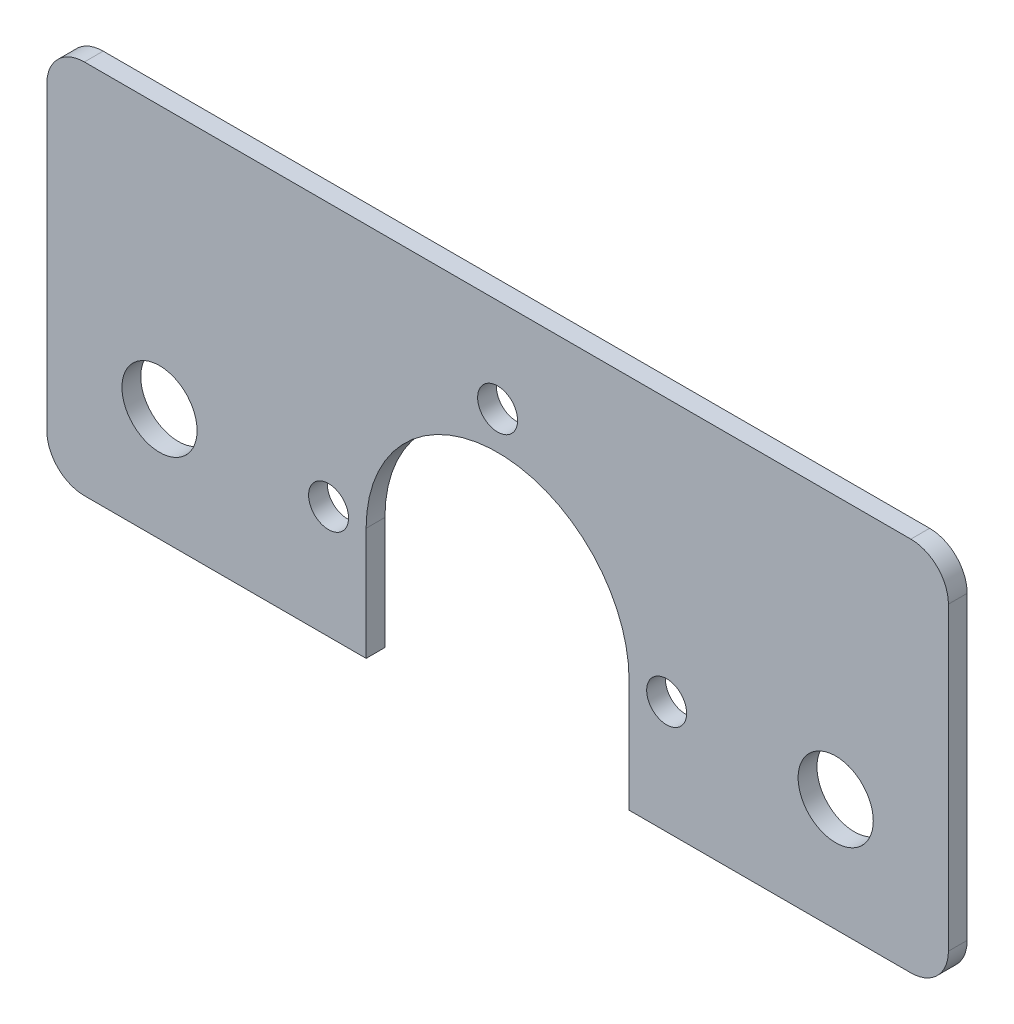
from build123d import *

# Parameters (mm, degrees)
SKETCH1_W           = 152.4
SKETCH1_H           = 88.9
SKETCH1_R           = 3.3782
SKETCH1_R_2         = 6.35
SKETCH1_R_3         = 22.225
BOSS_EXTRUDE1_DEPTH = 3.175
SKETCH2_R           = 3.3782
CUT_EXTRUDE1_DEPTH  = 4.175
SKETCH3_W           = 152.4
SKETCH3_H           = 25.4
CUT_EXTRUDE2_DEPTH  = 4.175
FILLET1_R           = 6.35


with BuildPart() as part:
    # Sketch1 → Boss-Extrude1 (new body)
    with BuildSketch(Plane.XY):
        Rectangle(SKETCH1_W, SKETCH1_H)
        with Locations((-28.575, 0)):
            Circle(SKETCH1_R, mode=Mode.SUBTRACT)
        with Locations((0, 28.575)):
            Circle(SKETCH1_R, mode=Mode.SUBTRACT)
        with Locations((28.575, 0)):
            Circle(SKETCH1_R, mode=Mode.SUBTRACT)
        with Locations((0, -28.575)):
            Circle(SKETCH1_R, mode=Mode.SUBTRACT)
        with Locations((-57.15, 0)):
            Circle(SKETCH1_R_2, mode=Mode.SUBTRACT)
        with Locations((57.15, 0)):
            Circle(SKETCH1_R_2, mode=Mode.SUBTRACT)
        Circle(SKETCH1_R_3, mode=Mode.SUBTRACT)
    extrude(amount=BOSS_EXTRUDE1_DEPTH)

    # Sketch2 → Cut-Extrude1 (cut, through all)
    with BuildSketch(Plane.XY.offset(3.175)):
        with BuildLine():
            Line((-28.575, -20.32), (-28.575, -44.45))
            Line((-28.575, -44.45), (28.575, -44.45))
            Line((28.575, -44.45), (28.575, -20.32))
            Line((28.575, -20.32), (22.225, -20.32))
            Line((22.225, -20.32), (9.002678768, -20.32))
            ThreePointArc((9.002678768, -20.32), (0, -22.225), (-9.002678768, -20.32))
            Line((-9.002678768, -20.32), (-22.225, -20.32))
            Line((-22.225, -20.32), (-28.575, -20.32))
        make_face()
        with Locations((0, -28.575)):
            Circle(SKETCH2_R, mode=Mode.SUBTRACT)
        with BuildLine():
            Line((-22.225, 0), (-22.225, -20.32))
            Line((-22.225, -20.32), (-9.002678768, -20.32))
            ThreePointArc((-9.002678768, -20.32), (-18.628407884, -12.121594148), (-22.225, 0))
        make_face()
        with BuildLine():
            Line((9.002678768, -20.32), (22.225, -20.32))
            Line((22.225, -20.32), (22.225, 0))
            ThreePointArc((22.225, 0), (18.628407884, -12.121594148), (9.002678768, -20.32))
        make_face()
        with BuildLine():
            ThreePointArc((-22.225, 0), (-18.628407884, -12.121594148), (-9.002678768, -20.32))
            Line((-9.002678768, -20.32), (9.002678768, -20.32))
            ThreePointArc((9.002678768, -20.32), (18.628407884, -12.121594148), (22.225, 0))
            Line((22.225, 0), (-22.225, 0))
        make_face()
        with BuildLine():
            Line((9.002678768, -20.32), (-9.002678768, -20.32))
            ThreePointArc((-9.002678768, -20.32), (0, -22.225), (9.002678768, -20.32))
        make_face()
    extrude(amount=-CUT_EXTRUDE1_DEPTH, mode=Mode.SUBTRACT)

    # Sketch3 → Cut-Extrude2 (cut, through all)
    with BuildSketch(Plane.XY.offset(3.175)):
        with Locations((0, -31.75)):
            Rectangle(SKETCH3_W, SKETCH3_H)
    extrude(amount=-CUT_EXTRUDE2_DEPTH, mode=Mode.SUBTRACT)

    # Fillet1
    fillet1_edges = [part.edges().sort_by_distance(p)[0] for p in [
        (-76.2, 44.45, 1.5875),
        (76.2, 44.45, 1.5875),
        (-76.2, -19.05, 1.5875),
        (76.2, -19.05, 1.5875),
    ]]
    fillet(fillet1_edges, radius=FILLET1_R)


solid = part.part
